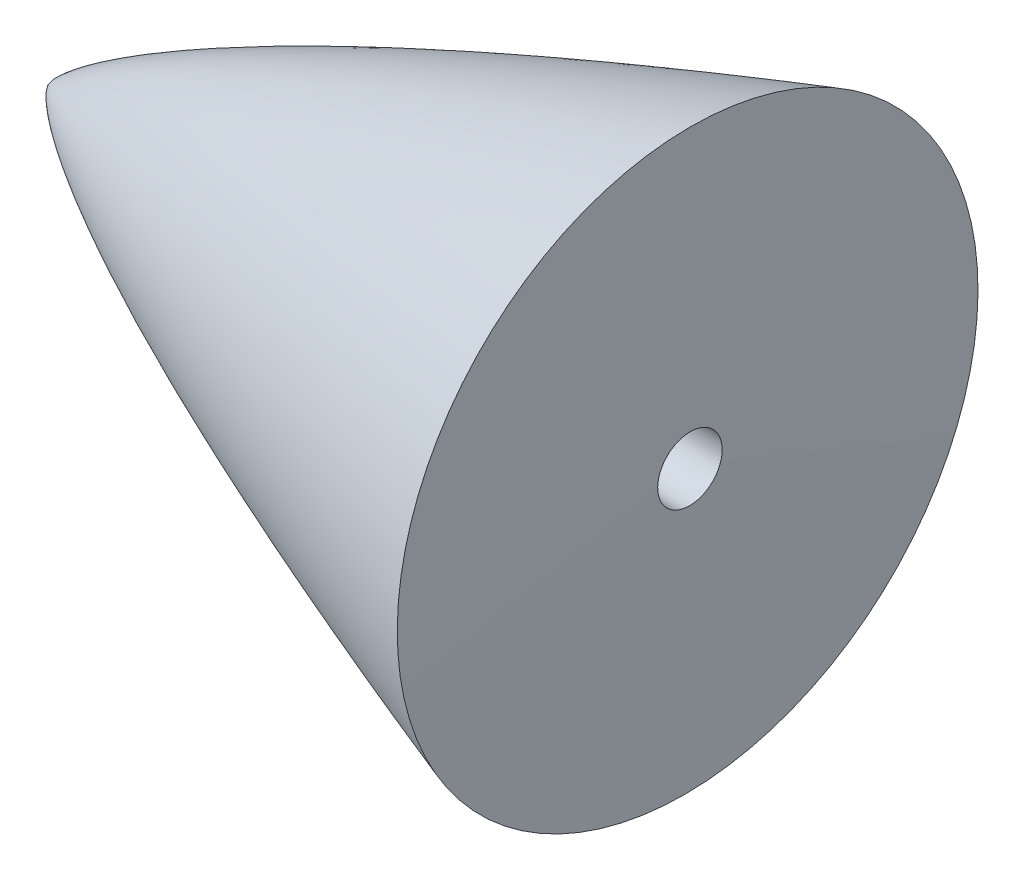
from build123d import *

# Parameters (mm, degrees)
F_1_4_20_TAPPED_HOLE2_D     = 5.1054
F_1_4_20_TAPPED_HOLE2_DEPTH = 25.4
F_1_4_20_TAPPED_HOLE2_TIP   = 1.533816902


with BuildPart() as part:
    # Sketch1 → Revolve3 (revolve)
    with BuildSketch(Plane.XY):
        with BuildLine():
            Line((0, 0), (50.8, -0.464446844))
            Line((50.8, -0.464446844), (50.8, 22.53035676))
            add(Edge.make_bspline(
                [(0, 0), (0.0034024, 0.01795031), (0.011072676, 0.044278315), (0.027596137, 0.082435683), (0.056361437, 0.139758553), (0.096892772, 0.209644329), (0.165033444, 0.31253391), (0.278299045, 0.462127291), (0.461319423, 0.674703688), (0.755145997, 0.975924583), (1.220793664, 1.398524844), (1.947952107, 1.984346248), (3.037572116, 2.766268991), (4.688342873, 3.828301188), (7.068662655, 5.203170594), (10.093640064, 6.782328502), (13.641340019, 8.482738948), (17.461723673, 10.190494576), (21.314012071, 11.819449827), (25.19561798, 13.38603627), (28.605275599, 14.708692688), (31.546737573, 15.816610987), (33.991560363, 16.718530148), (35.973631638, 17.437875886), (37.913686765, 18.133254468), (39.93420744, 18.845521365), (42.317049575, 19.677594775), (44.94498249, 20.575969254), (47.177380459, 21.331077534), (49.442710435, 22.082930839), (50.346511785, 22.381251238), (50.8, 22.53035676)],
                knots=[0, 0, 0, 0, 0, 0.001189539, 0.001792644, 0.002702282, 0.004188017, 0.006457458, 0.009843452, 0.01494001, 0.02248545, 0.033904004, 0.050862967, 0.075850775, 0.109982129, 0.161962073, 0.230225004, 0.298487914, 0.366750854, 0.435013781, 0.503276713, 0.571539643, 0.605671108, 0.639802574, 0.673934039, 0.708065504, 0.742196969, 0.776328435, 0.844591364, 0.87872283, 0.912854295, 0.912854295, 0.912854295, 0.912854295, 0.912854295], degree=4))
        make_face()
    revolve(axis=Axis((0, 0, 0), (0.999958209, -0.009142272, 0)))

    # 1/4-20 Tapped Hole2
    with Locations(Plane(origin=(50.791508156, -0.928816049, 3.529e-06), x_dir=(0.01828378, 0.999832838, 0), z_dir=(0.999832838, -0.01828378, 6.9e-08))):
        with Locations((0, 0)):
            Hole(F_1_4_20_TAPPED_HOLE2_D / 2, depth=F_1_4_20_TAPPED_HOLE2_DEPTH)
            with Locations((0, 0, -(F_1_4_20_TAPPED_HOLE2_DEPTH + F_1_4_20_TAPPED_HOLE2_TIP / 2))):  # 118° drill point
                Cone(0, F_1_4_20_TAPPED_HOLE2_D / 2, F_1_4_20_TAPPED_HOLE2_TIP, mode=Mode.SUBTRACT)


solid = part.part
